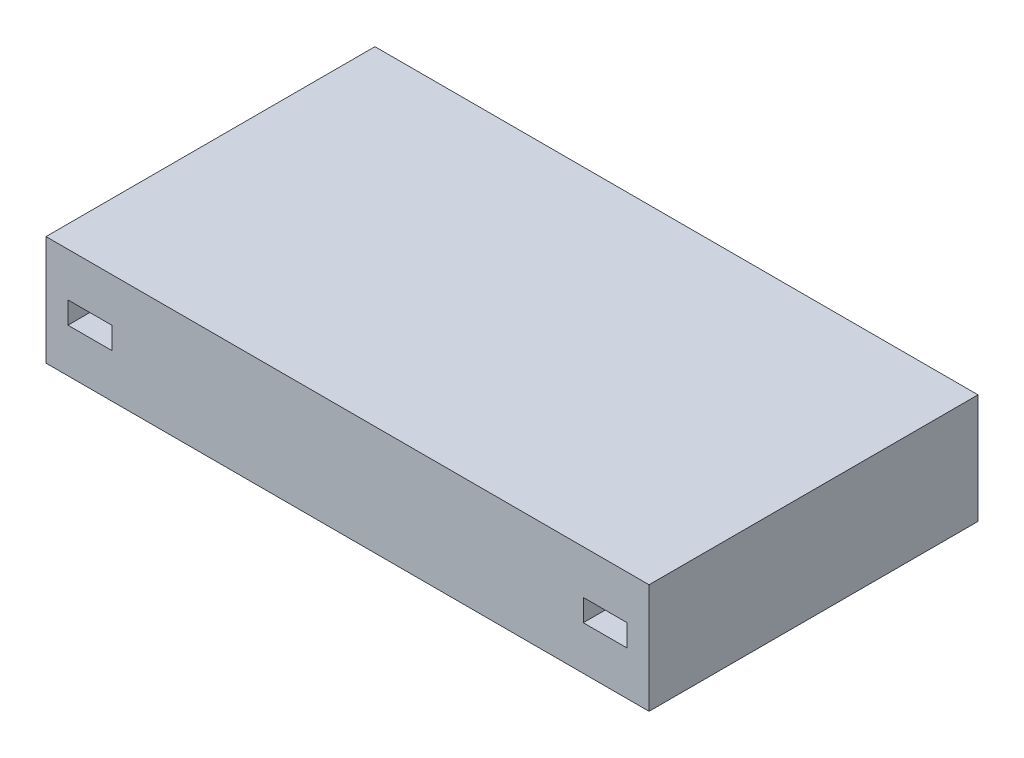
from build123d import *

# Parameters (mm, degrees)
SKETCH1_W           = 300
SKETCH1_H           = 100
BOSS_EXTRUDE1_DEPTH = 550
SKETCH2_W           = 40
SKETCH2_H           = 20
CUT_EXTRUDE1_DEPTH  = 25


with BuildPart() as part:
    # Sketch1 → Boss-Extrude1 (new body)
    with BuildSketch(Plane(origin=(0, 0, 0), x_dir=(0, 0, -1), z_dir=(1, 0, 0))):
        with Locations((150, 50)):
            Rectangle(SKETCH1_W, SKETCH1_H)
    extrude(amount=BOSS_EXTRUDE1_DEPTH)

    # Sketch2 → Cut-Extrude1 (cut)
    with BuildSketch(Plane.XY):
        with Locations((40, 50)):
            Rectangle(SKETCH2_W, SKETCH2_H)
        with Locations((510, 50)):
            Rectangle(SKETCH2_W, SKETCH2_H)
    cut_extrude1 = extrude(amount=-CUT_EXTRUDE1_DEPTH, mode=Mode.SUBTRACT)

    # Mirror1: Cut-Extrude1 across plane
    add(cut_extrude1.mirror(Plane.XY.offset(-150)), mode=Mode.SUBTRACT)


solid = part.part
